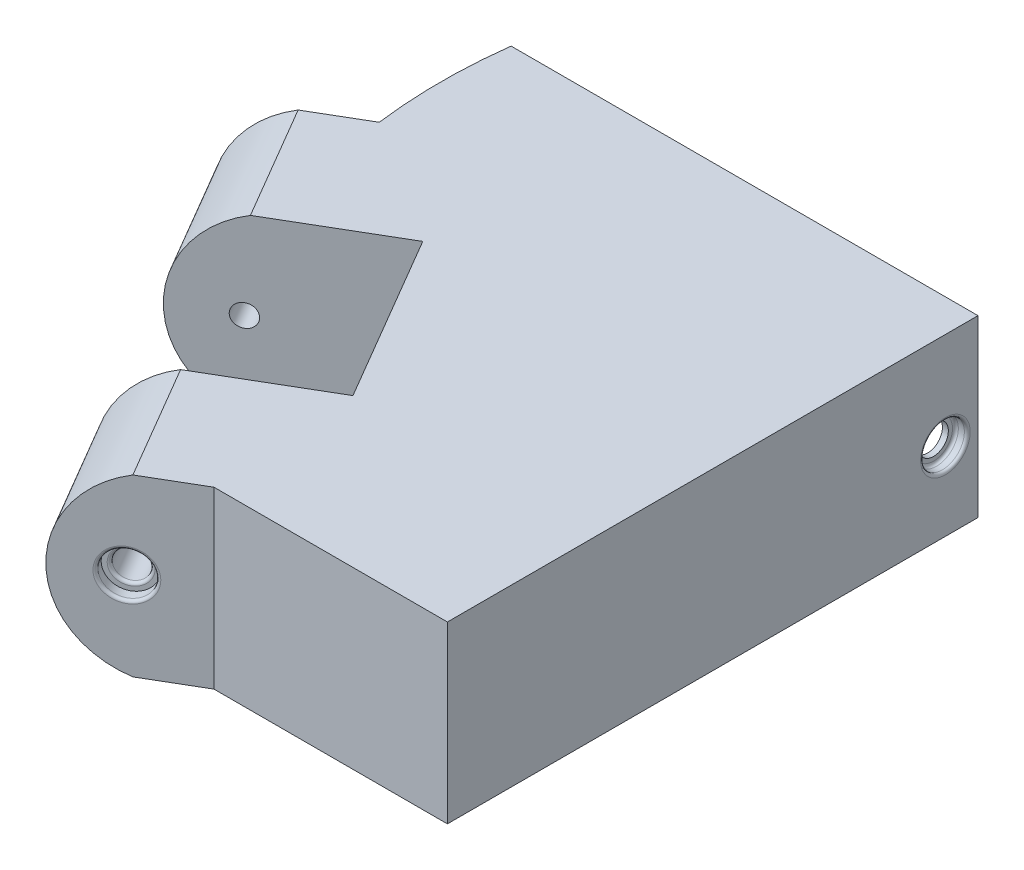
from build123d import *

# Parameters (mm, degrees)
BOSS_EXTRUDE2_DEPTH                             = 29.972
EXTRUDE_THIN2_DEPTH                             = 29.972
BOSS_EXTRUDE3_DEPTH                             = 22.86
BOSS_EXTRUDE4_DEPTH                             = 22.86
SKETCH12_R                                      = 1.905
CUT_EXTRUDE2_DEPTH                              = 111.410659875
BOSS_EXTRUDE6_DEPTH                             = 29.972
CBORE_FOR_6_PAN_HEAD_MACHINE_SCREW1_D           = 3.7500052
CBORE_FOR_6_PAN_HEAD_MACHINE_SCREW1_CBORE_D     = 7.5000104
CBORE_FOR_6_PAN_HEAD_MACHINE_SCREW1_CBORE_DEPTH = 2.032
CUT_EXTRUDE4_REACH                              = 107.839
SKETCH18_R                                      = 2.5
FILLET1_R                                       = 0.5
SKETCH19_W                                      = 73.969126852
SKETCH19_H                                      = 25.4
CUT_EXTRUDE5_DEPTH                              = 22.86
CUT_EXTRUDE7_START                              = -80.649491
SKETCH21_R                                      = 1.905
CUT_EXTRUDE7_DEPTH                              = 80.649491
CBORE_FOR_6_PAN_HEAD_MACHINE_SCREW2_D           = 3.7500052
CBORE_FOR_6_PAN_HEAD_MACHINE_SCREW2_CBORE_D     = 7.5000104
CBORE_FOR_6_PAN_HEAD_MACHINE_SCREW2_CBORE_DEPTH = 2.032
SKETCH26_R                                      = 2.54
CUT_EXTRUDE9_DEPTH                              = 3.048
FILLET3_R                                       = 0.5
CUT_EXTRUDE11_DEPTH                             = 29.972


with BuildPart() as part:
    # Sketch1 → Boss-Extrude2 (new body)
    with BuildSketch(Plane(origin=(0, 0, 0), x_dir=(1, 0, 0), z_dir=(0, 1, 0))):
        Polygon((-40.005, 45.466), (-40.005, 22.86), (0, -45.466), (40.005, -45.466), (40.005, 45.466), align=None)
    extrude(amount=BOSS_EXTRUDE2_DEPTH)

    # Sketch8 → Extrude-Thin2 (add)
    with BuildSketch(Plane(origin=(0, 0, 0), x_dir=(1, 0, 0), z_dir=(0, 1, 0))):
        Polygon((-40.005, 22.86), (-28.454605215, 3.132659066), (-37.222312297, -2.000849727), (-48.772707082, 17.726491207), align=None)
        Polygon((-11.550394785, -25.738659066), (0, -45.466), (-8.767707082, -50.599508793), (-20.318101866, -30.872167859), align=None)
    extrude(amount=EXTRUDE_THIN2_DEPTH)

    # Sketch10 → Boss-Extrude3 (add)
    with BuildSketch(Plane(origin=(19.824382752, 0, 33.85878705), x_dir=(0.862963295, 0, -0.505266614), z_dir=(0.505266614, 0, 0.862963295))):
        with BuildLine():
            Line((-33.132451849, 29.972), (-33.132451849, 0))
            ThreePointArc((-33.132451849, 0), (-44.041101893, 14.986), (-33.132451849, 29.972))
        make_face()
    extrude(amount=-BOSS_EXTRUDE3_DEPTH)

    # Sketch11 → Boss-Extrude4 (add)
    with BuildSketch(Plane(origin=(-8.630222463, 0, -14.739872016), x_dir=(0.862963295, 0, -0.505266614), z_dir=(0.505266614, 0, 0.862963295))):
        with BuildLine():
            Line((-33.132451849, 0), (-33.132451849, 29.972))
            ThreePointArc((-33.132451849, 29.972), (-44.041101893, 14.986), (-33.132451849, 0))
        make_face()
    extrude(amount=-BOSS_EXTRUDE4_DEPTH)

    # Sketch12 → Cut-Extrude2 (cut, through all)
    with BuildSketch(Plane(origin=(21.107759951, 0, 36.050713821), x_dir=(0.862963295, 0, -0.505266614), z_dir=(0.505266614, 0, 0.862963295))):
        with Locations((-33.881101893, 14.986)):
            Circle(SKETCH12_R)
    extrude(amount=-CUT_EXTRUDE2_DEPTH, mode=Mode.SUBTRACT)

    # Sketch15 → Boss-Extrude6 (add)
    with BuildSketch(Plane(origin=(0, 29.972, 0), x_dir=(1, 0, 0), z_dir=(0, 1, 0))):
        with BuildLine():
            Line((-40.005, 45.466), (-40.005, 22.86))
            ThreePointArc((-40.005, 22.86), (-40.726132774, 34.163), (-40.005, 45.466))
        make_face()
    extrude(amount=-BOSS_EXTRUDE6_DEPTH)

    # CBORE for #6 Pan Head Machine Screw1 (through all)
    with Locations(Plane(origin=(19.824382752, 0, 33.85878705), x_dir=(0.862963295, 0, -0.505266614), z_dir=(0.505266614, 0, 0.862963295))):
        with Locations((-33.881101893, 14.986)):
            CounterBoreHole(CBORE_FOR_6_PAN_HEAD_MACHINE_SCREW1_D / 2, CBORE_FOR_6_PAN_HEAD_MACHINE_SCREW1_CBORE_D / 2, CBORE_FOR_6_PAN_HEAD_MACHINE_SCREW1_CBORE_DEPTH)

    # Sketch18 → Cut-Extrude4 (cut, up to next)
    with BuildSketch(Plane(origin=(18.797680994, 0, 32.105245634), x_dir=(0.862963295, 0, -0.505266614), z_dir=(0.505266614, 0, 0.862963295)), mode=Mode.PRIVATE) as cut_extrude4_sk1:
        with Locations((-33.881101893, 14.986)):
            Circle(SKETCH18_R)
    cut_extrude4_tool1 = extrude(cut_extrude4_sk1.sketch, amount=-CUT_EXTRUDE4_REACH, mode=Mode.PRIVATE) & part.part
    add(cut_extrude4_tool1.solids().sort_by_distance((-10.440466, 14.986, 49.224235))[0], mode=Mode.SUBTRACT)

    # Fillet1
    fillet1_edges = [part.edges().sort_by_distance(p)[0] for p in [
        (-12.649881436, 14.986, 52.872529093),
        (-12.597874588, 14.986, 50.487401783),
    ]]
    fillet(fillet1_edges, radius=FILLET1_R)

    # Sketch19 → Cut-Extrude5 (cut)
    with BuildSketch(Plane(origin=(0, 0, -45.466), x_dir=(-1, 0, 0), z_dir=(0, 0, -1))):
        with Locations((0.027563426, 12.7)):
            Rectangle(SKETCH19_W, SKETCH19_H)
    extrude(amount=-CUT_EXTRUDE5_DEPTH, mode=Mode.SUBTRACT)

    # Sketch21 → Cut-Extrude7 (cut)
    with BuildSketch(Plane(origin=(40.005, 0, 0), x_dir=(0, 0, -1), z_dir=(1, 0, 0)).offset(CUT_EXTRUDE7_START)):
        with Locations((39.878, 13.391837379)):
            Circle(SKETCH21_R)
    extrude(amount=CUT_EXTRUDE7_DEPTH, mode=Mode.SUBTRACT)

    # CBORE for #6 Pan Head Machine Screw2 (through all)
    with Locations(Plane(origin=(40.005, 0, 0), x_dir=(0, 0, -1), z_dir=(1, 0, 0))):
        with Locations((39.878, 13.391837379)):
            CounterBoreHole(CBORE_FOR_6_PAN_HEAD_MACHINE_SCREW2_D / 2, CBORE_FOR_6_PAN_HEAD_MACHINE_SCREW2_CBORE_D / 2, CBORE_FOR_6_PAN_HEAD_MACHINE_SCREW2_CBORE_DEPTH)

    # Sketch26 → Cut-Extrude9 (cut)
    with BuildSketch(Plane(origin=(40.005, 0, 0), x_dir=(0, 0, -1), z_dir=(1, 0, 0))):
        with Locations(Location((39.878, 13.391837379, 0), (0, 0, 180))):  # turned: the seam where the file's is
            Circle(SKETCH26_R)
    extrude(amount=-CUT_EXTRUDE9_DEPTH, mode=Mode.SUBTRACT)

    # Fillet3
    fillet3_edges = [part.edges().sort_by_distance(p)[0] for p in [
        (40.005, 13.391837379, -36.1279948),
        (37.973, 13.391837379, -36.1279948),
    ]]
    fillet(fillet3_edges, radius=FILLET3_R)

    # Sketch28 → Cut-Extrude11 (cut)
    with BuildSketch(Plane(origin=(0, 29.972, 0), x_dir=(1, 0, 0), z_dir=(0, 1, 0))):
        Polygon((-11.550394785, -25.738659066), (-1.686724318, -19.963461674), (-18.590934748, 8.907856459), (-28.454605215, 3.132659066), align=None)
    extrude(amount=-CUT_EXTRUDE11_DEPTH, mode=Mode.SUBTRACT)


solid = part.part
